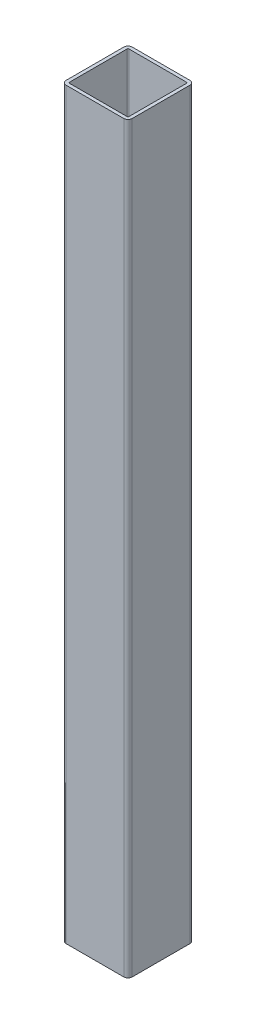
from build123d import *

# Parameters (mm, degrees)
EXTRUDE_1_DEPTH = 900


with BuildPart() as part:
    # Эскиз1 → Вытянуть-Тонкостенный1 (new body)
    with BuildSketch(Plane(origin=(0, 0, 0), x_dir=(1, 0, 0), z_dir=(0, 1, 0))):
        with BuildLine():
            Line((-35, 40), (35, 40))
            ThreePointArc((35, 40), (38.535533906, 38.535533906), (40, 35))
            Line((40, 35), (40, -35))
            ThreePointArc((40, -35), (38.535533906, -38.535533906), (35, -40))
            Line((35, -40), (-35, -40))
            ThreePointArc((-35, -40), (-38.535533906, -38.535533906), (-40, -35))
            Line((-40, -35), (-40, 35))
            ThreePointArc((-40, 35), (-38.535533906, 38.535533906), (-35, 40))
        make_face()
        with BuildLine():
            Line((-35, 36), (35, 36))
            ThreePointArc((35, 36), (35.707106781, 35.707106781), (36, 35))
            Line((36, 35), (36, -35))
            ThreePointArc((36, -35), (35.707106781, -35.707106781), (35, -36))
            Line((35, -36), (-35, -36))
            ThreePointArc((-35, -36), (-35.707106781, -35.707106781), (-36, -35))
            Line((-36, -35), (-36, 35))
            ThreePointArc((-36, 35), (-35.707106781, 35.707106781), (-35, 36))
        make_face(mode=Mode.SUBTRACT)
    extrude(amount=EXTRUDE_1_DEPTH)


solid = part.part
